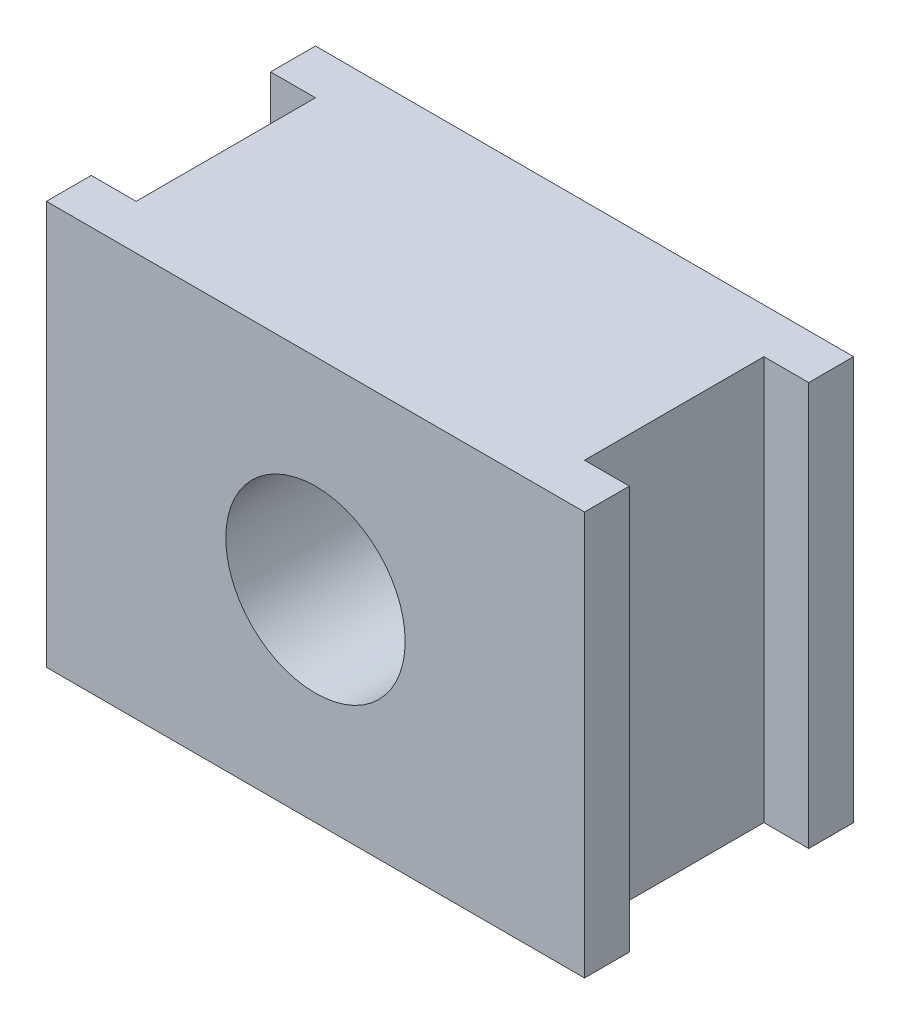
from build123d import *

# Parameters (mm, degrees)
SKETCH_1_W          = 60
SKETCH_1_H          = 45
EXTRUDE_1_DEPTH     = 30
SKETCH_2_W          = 15
SKETCH_2_H          = 20
CUT_EXTRUDE_1_DEPTH = 80
SKETCH_3_R          = 10
CUT_EXTRUDE_2_DEPTH = 80


with BuildPart() as part:
    # 草图1 → 凸台-拉伸1 (new body)
    with BuildSketch(Plane.XY):
        Rectangle(SKETCH_1_W, SKETCH_1_H)
    extrude(amount=EXTRUDE_1_DEPTH)

    # 草图2 → 切除-拉伸1 (cut)
    with BuildSketch(Plane(origin=(0, 22.5, 0), x_dir=(1, 0, 0), z_dir=(0, 1, 0))):
        with Locations((-32.5, -15)):
            Rectangle(SKETCH_2_W, SKETCH_2_H)
        with Locations((32.5, -15)):
            Rectangle(SKETCH_2_W, SKETCH_2_H)
    extrude(amount=-CUT_EXTRUDE_1_DEPTH, mode=Mode.SUBTRACT)

    # 草图3 → 切除-拉伸2 (cut)
    with BuildSketch(Plane.XY.offset(30)):
        Circle(SKETCH_3_R)
    extrude(amount=-CUT_EXTRUDE_2_DEPTH, mode=Mode.SUBTRACT)


solid = part.part
